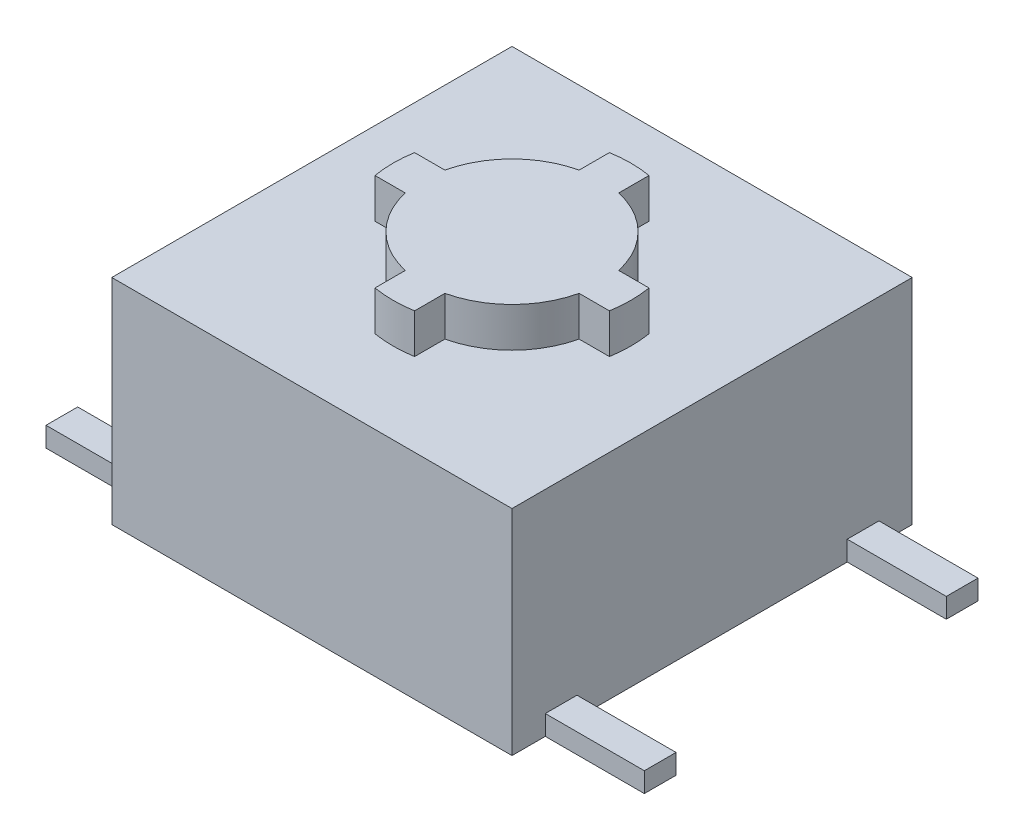
from build123d import *

# Parameters (mm, degrees)
SKETCH1_W           = 10.1
SKETCH1_H           = 10.1
BOSS_EXTRUDE1_DEPTH = 5.4
SKETCH2_W           = 1
SKETCH2_H           = 1
BOSS_EXTRUDE2_DEPTH = 1
SKETCH3_W           = 2.5
SKETCH3_H           = 0.8
BOSS_EXTRUDE3_DEPTH = 0.5


with BuildPart() as part:
    # Sketch1 → Boss-Extrude1 (new body)
    with BuildSketch(Plane(origin=(0, 0, 0), x_dir=(1, 0, 0), z_dir=(0, 1, 0))):
        Rectangle(SKETCH1_W, SKETCH1_H)
    extrude(amount=BOSS_EXTRUDE1_DEPTH)

    # Sketch2 → Boss-Extrude2 (add)
    with BuildSketch(Plane(origin=(0, 5.4, 0), x_dir=(1, 0, 0), z_dir=(0, 1, 0))):
        with BuildLine():
            ThreePointArc((0.5, 2.958039892), (0, 3), (-0.5, 2.958039892))
            Line((-0.5, 2.958039892), (-0.5, 2.193741097))
            ThreePointArc((-0.5, 2.193741097), (0, 2.25), (0.5, 2.193741097))
            Line((0.5, 2.193741097), (0.5, 2.958039892))
        make_face()
        with BuildLine():
            Line((-0.5, -2.193741097), (-0.5, -2.958039892))
            ThreePointArc((-0.5, -2.958039892), (0, -3), (0.5, -2.958039892))
            Line((0.5, -2.958039892), (0.5, -2.193741097))
            ThreePointArc((0.5, -2.193741097), (0, -2.25), (-0.5, -2.193741097))
        make_face()
        with BuildLine():
            ThreePointArc((0.5, 2.193741097), (0, 2.25), (-0.5, 2.193741097))
            Line((-0.5, 2.193741097), (-0.5, 0.5))
            Line((-0.5, 0.5), (0.5, 0.5))
            Line((0.5, 0.5), (0.5, 2.193741097))
        make_face()
        with BuildLine():
            Line((-0.5, 0.5), (-0.5, 2.193741097))
            ThreePointArc((-0.5, 2.193741097), (-1.590990258, 1.590990258), (-2.193741097, 0.5))
            Line((-2.193741097, 0.5), (-0.5, 0.5))
        make_face()
        with BuildLine():
            Line((-0.5, -0.5), (-0.5, 0.5))
            Line((-0.5, 0.5), (-2.193741097, 0.5))
            ThreePointArc((-2.193741097, 0.5), (-2.25, 0), (-2.193741097, -0.5))
            Line((-2.193741097, -0.5), (-0.5, -0.5))
        make_face()
        with BuildLine():
            Line((-2.193741097, 0.5), (-2.958039892, 0.5))
            ThreePointArc((-2.958039892, 0.5), (-3, 0), (-2.958039892, -0.5))
            Line((-2.958039892, -0.5), (-2.193741097, -0.5))
            ThreePointArc((-2.193741097, -0.5), (-2.25, 0), (-2.193741097, 0.5))
        make_face()
        with BuildLine():
            ThreePointArc((3, 0), (2.989491568, 0.250878781), (2.958039892, 0.5))
            Line((2.958039892, 0.5), (2.193741097, 0.5))
            ThreePointArc((2.193741097, 0.5), (2.235891038, 0.251577555), (2.25, 0))
            ThreePointArc((2.25, 0), (2.235891038, -0.251577555), (2.193741097, -0.5))
            Line((2.193741097, -0.5), (2.958039892, -0.5))
            ThreePointArc((2.958039892, -0.5), (2.989491568, -0.250878781), (3, 0))
        make_face()
        with BuildLine():
            Line((0.5, -0.5), (-0.5, -0.5))
            Line((-0.5, -0.5), (-0.5, -2.193741097))
            ThreePointArc((-0.5, -2.193741097), (0, -2.25), (0.5, -2.193741097))
            Line((0.5, -2.193741097), (0.5, -0.5))
        make_face()
        Rectangle(SKETCH2_W, SKETCH2_H)
        with BuildLine():
            Line((2.193741097, 0.5), (0.5, 0.5))
            Line((0.5, 0.5), (0.5, -0.5))
            Line((0.5, -0.5), (2.193741097, -0.5))
            ThreePointArc((2.193741097, -0.5), (2.235891038, -0.251577555), (2.25, 0))
            ThreePointArc((2.25, 0), (2.235891038, 0.251577555), (2.193741097, 0.5))
        make_face()
        with BuildLine():
            ThreePointArc((2.193741097, 0.5), (1.590990258, 1.590990258), (0.5, 2.193741097))
            Line((0.5, 2.193741097), (0.5, 0.5))
            Line((0.5, 0.5), (2.193741097, 0.5))
        make_face()
        with BuildLine():
            Line((2.193741097, -0.5), (0.5, -0.5))
            Line((0.5, -0.5), (0.5, -2.193741097))
            ThreePointArc((0.5, -2.193741097), (1.590990258, -1.590990258), (2.193741097, -0.5))
        make_face()
        with BuildLine():
            Line((-0.5, -2.193741097), (-0.5, -0.5))
            Line((-0.5, -0.5), (-2.193741097, -0.5))
            ThreePointArc((-2.193741097, -0.5), (-1.590990258, -1.590990258), (-0.5, -2.193741097))
        make_face()
    extrude(amount=BOSS_EXTRUDE2_DEPTH)

    # Sketch3 → Boss-Extrude3 (add)
    with BuildSketch(Plane.XZ):
        with Locations((-6.3, 3.81)):
            Rectangle(SKETCH3_W, SKETCH3_H)
        with Locations((6.3, 3.81)):
            Rectangle(SKETCH3_W, SKETCH3_H)
        with Locations((6.3, -3.81)):
            Rectangle(SKETCH3_W, SKETCH3_H)
        with Locations((-6.3, -3.81)):
            Rectangle(SKETCH3_W, SKETCH3_H)
    extrude(amount=-BOSS_EXTRUDE3_DEPTH)


solid = part.part
